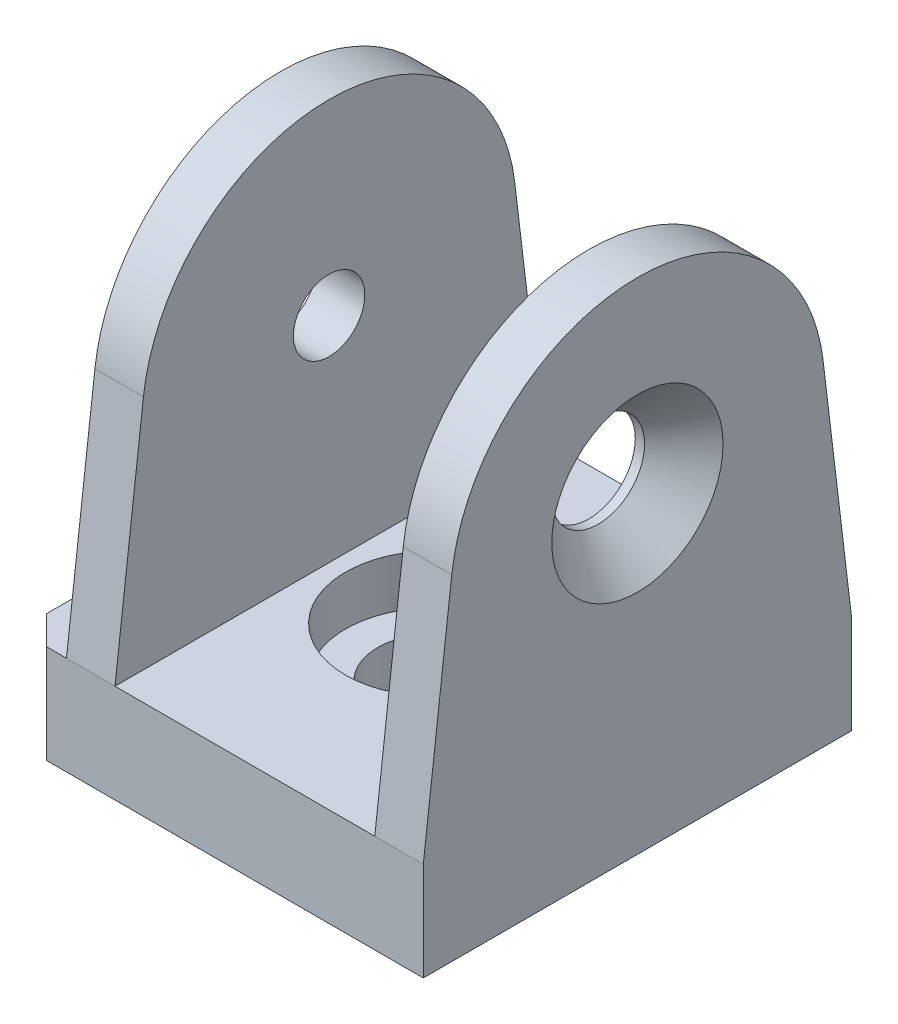
from build123d import *

# Parameters (mm, degrees)
SKETCH_1_W               = 28.4
SKETCH_1_H               = 30
EXTRUDE_1_DEPTH          = 6.9
EXTRUDE_2_DEPTH          = 25
SKETCH_4_W               = 18.2
SKETCH_4_H               = 28.1
CUT_EXTRUDE_1_DEPTH      = 16
CUT_EXTRUDE_1_DEPTH_BACK = 16
CHAMFER_1_SIZE           = 2
HOLE_WIZARD_M61_D        = 5
HOLE_WIZARD_M61_DEPTH    = 3.4


with BuildPart() as part:
    # Эскиз1 → Бобышка-Вытянуть1 (new body)
    with BuildSketch(Plane(origin=(0, 0, 0), x_dir=(1, 0, 0), z_dir=(0, 1, 0))):
        Rectangle(SKETCH_1_W, SKETCH_1_H)
    extrude(amount=EXTRUDE_1_DEPTH)

    # Эскиз2 → Вырез-Повернуть1 (revolve, cut)
    with BuildSketch(Plane.XY, mode=Mode.PRIVATE) as cut_revolve_1_sk:
        Polygon((-4, 0), (-4, 3.45), (-6.25, 3.45), (-6.25, 6.9), (0, 6.9), (0, 0), align=None)
    revolve(cut_revolve_1_sk.sketch.rotate(Axis((0, 6.9, 0), (0, -1, 0)), 270), axis=Axis((0, 6.9, 0), (0, -1, 0)), mode=Mode.SUBTRACT)  # turned: the seam where the file's is

    # Эскиз3 → Бобышка-Вытянуть2 (add)
    with BuildSketch(Plane(origin=(14.2, 0, 0), x_dir=(0, 0, -1), z_dir=(1, 0, 0))):
        with BuildLine():
            Line((-15, 6.9), (-13.006126808, 23.465460141))
            ThreePointArc((-13.006126808, 23.465460141), (0, 35), (13.006126808, 23.465460141))
            Line((13.006126808, 23.465460141), (15, 6.9))
            Line((15, 6.9), (-15, 6.9))
        make_face()
    extrude(amount=-EXTRUDE_2_DEPTH)

    # Эскиз4 → Вырез-Вытянуть1 (cut, two sides)
    with BuildSketch(Plane.XY) as cut_extrude_1_sk:
        with Locations((1.7, 20.95)):
            Rectangle(SKETCH_4_W, SKETCH_4_H)
    extrude(amount=CUT_EXTRUDE_1_DEPTH, mode=Mode.SUBTRACT)
    extrude(cut_extrude_1_sk.sketch, amount=-CUT_EXTRUDE_1_DEPTH_BACK, mode=Mode.SUBTRACT)

    # Фаска1
    chamfer_1_edges = [part.edges().sort_by_distance(p)[0] for p in [
        (-14.2, 3.45, -15),
        (-14.2, 3.45, 15),
    ]]
    chamfer(chamfer_1_edges, length=CHAMFER_1_SIZE)

    # Отверстие обработанное метчиком M61
    with Locations(Plane.ZY.offset(10.8)):
        with Locations((0, 21.9)):
            Hole(HOLE_WIZARD_M61_D / 2, depth=HOLE_WIZARD_M61_DEPTH)

    # Эскиз10 → Зенковка для винта с полупотайной головкой 1 (revolve, cut)
    with BuildSketch(Plane(origin=(14.2, 21.9, 0), x_dir=(0, 0, -1), z_dir=(0, 1, 0))):
        Polygon((0, 0), (0, 3.4), (3.25, 3.4), (3.25, 2.75), (6, 0), align=None)
    revolve(axis=Axis((20.55, 21.9, 0), (-1, 0, 0)), mode=Mode.SUBTRACT)


solid = part.part
